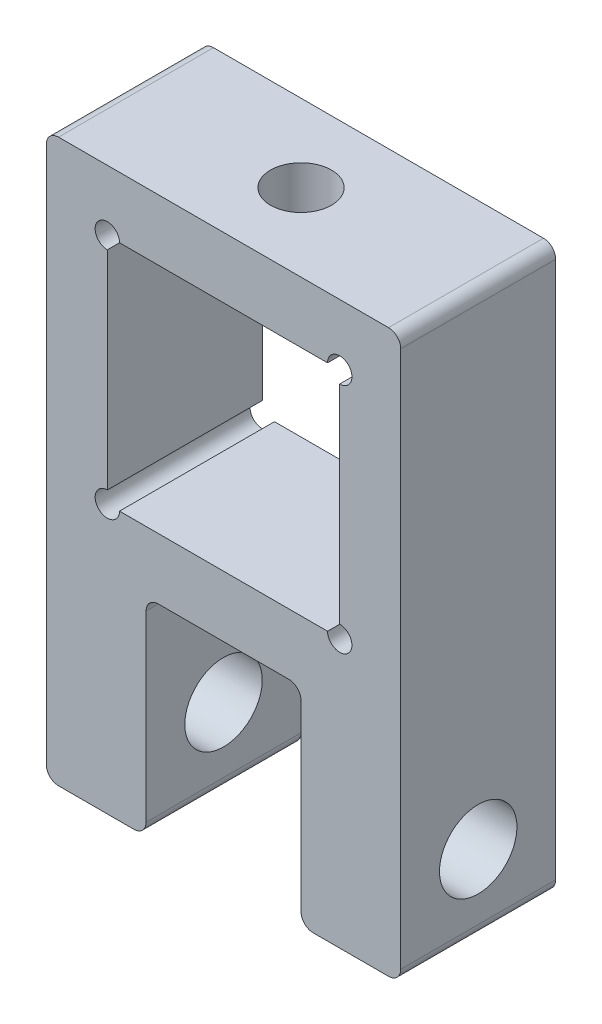
from build123d import *

# Parameters (mm, degrees)
BOSS_EXTRU_1_DEPTH           = 12.7
ESQUISSE2_R                  = 3.175
ENL_V_MAT_EXTRU_1_DEPTH      = 21.875
ENL_V_MAT_EXTRU_1_DEPTH_BACK = 9.175
CONG_2_R                     = 1
ENL_V_MAT_EXTRU_2_REACH      = 48.05
ESQUISSE3_R                  = 2.5


with BuildPart() as part:
    # Esquisse1 → Boss.-Extru.1 (new body)
    with BuildSketch(Plane.XY):
        with BuildLine():
            Line((0, 41.05), (0, 46.05))
            Line((0, 46.05), (-14.525, 46.05))
            Line((-14.525, 46.05), (-14.525, 0))
            Line((-14.525, 0), (-6.35, 0))
            Line((-6.35, 0), (-6.35, 17))
            Line((-6.35, 17), (0, 17))
            Line((0, 17), (0, 22))
            Line((0, 22), (-8.525, 22))
            ThreePointArc((-8.525, 22), (-10.232106781, 21.292893219), (-9.525, 23))
            Line((-9.525, 23), (-9.525, 40.05))
            ThreePointArc((-9.525, 40.05), (-10.232106781, 41.757106781), (-8.525, 41.05))
            Line((-8.525, 41.05), (0, 41.05))
        make_face()
        with BuildLine():
            Line((14.525, 0), (14.525, 46.05))
            Line((14.525, 46.05), (0, 46.05))
            Line((0, 46.05), (0, 41.05))
            Line((0, 41.05), (8.525, 41.05))
            ThreePointArc((8.525, 41.05), (9.525, 42.05), (10.525, 41.05))
            ThreePointArc((10.525, 41.05), (10.232106781, 40.342893219), (9.525, 40.05))
            Line((9.525, 40.05), (9.525, 23))
            ThreePointArc((9.525, 23), (10.232106781, 22.707106781), (10.525, 22))
            ThreePointArc((10.525, 22), (9.525, 21), (8.525, 22))
            Line((8.525, 22), (0, 22))
            Line((0, 22), (0, 17))
            Line((0, 17), (6.35, 17))
            Line((6.35, 17), (6.35, 0))
            Line((6.35, 0), (14.525, 0))
        make_face()
    extrude(amount=BOSS_EXTRU_1_DEPTH)

    # Esquisse2 → Enlèv. mat.-Extru.1 (cut, two sides)
    with BuildSketch(Plane(origin=(-6.35, 0, 0), x_dir=(0, 0, -1), z_dir=(1, 0, 0))) as enl_v_mat_extru_1_sk:
        with Locations((-6.35, 6.35)):
            Circle(ESQUISSE2_R)
    extrude(amount=ENL_V_MAT_EXTRU_1_DEPTH, mode=Mode.SUBTRACT)
    extrude(enl_v_mat_extru_1_sk.sketch, amount=-ENL_V_MAT_EXTRU_1_DEPTH_BACK, mode=Mode.SUBTRACT)

    # Congé2
    cong_2_edges = [part.edges().sort_by_distance(p)[0] for p in [
        (14.525, 0, 6.35),
        (6.35, 0, 6.35),
        (6.35, 17, 6.35),
        (-6.35, 17, 6.35),
        (-6.35, 0, 6.35),
        (-14.525, 0, 6.35),
        (-14.525, 46.05, 6.35),
        (14.525, 46.05, 6.35),
    ]]
    fillet(cong_2_edges, radius=CONG_2_R)

    # Esquisse3 → Enlèv. mat.-Extru.2 (cut, up to next)
    with BuildSketch(Plane(origin=(0, 46.05, 0), x_dir=(1, 0, 0), z_dir=(0, 1, 0)), mode=Mode.PRIVATE) as enl_v_mat_extru_2_sk1:
        with Locations((0, -6.35)):
            Circle(ESQUISSE3_R)
    enl_v_mat_extru_2_tool1 = extrude(enl_v_mat_extru_2_sk1.sketch, amount=-ENL_V_MAT_EXTRU_2_REACH, mode=Mode.PRIVATE) & part.part
    add(enl_v_mat_extru_2_tool1.solids().sort_by_distance((0, 46.05, 6.35))[0], mode=Mode.SUBTRACT)


solid = part.part
